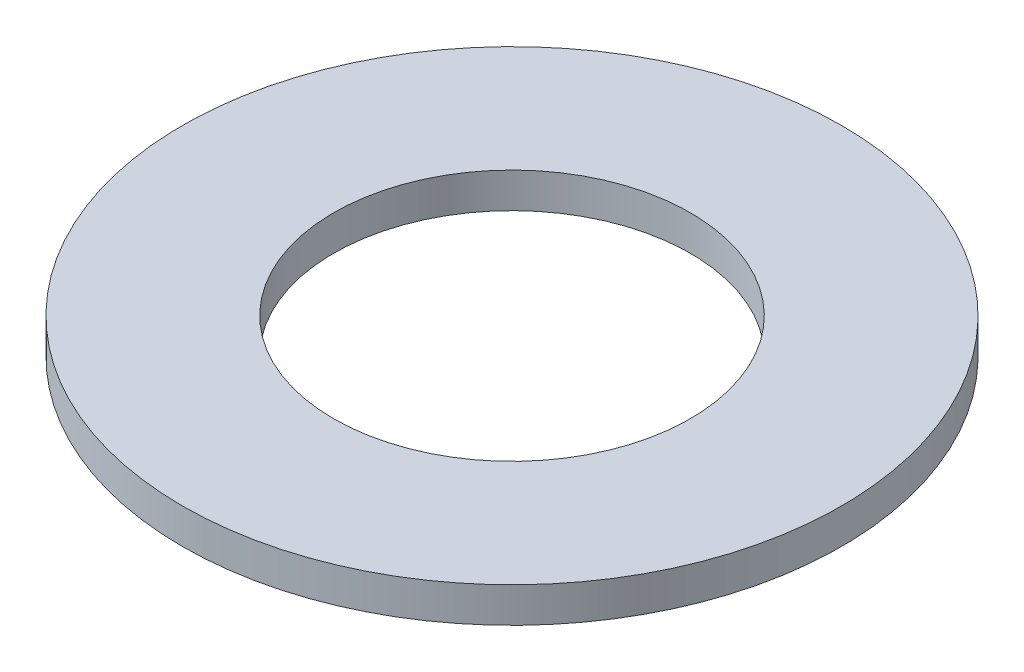
from build123d import *

# Parameters (mm, degrees)
SKETCH1_R           = 9.525
BOSS_EXTRUDE1_DEPTH = 1.016
SKETCH5_R           = 5.1562
CUT_EXTRUDE1_DEPTH  = 2.016


with BuildPart() as part:
    # Sketch1 → Boss-Extrude1 (new body)
    with BuildSketch(Plane(origin=(0, 0, 0), x_dir=(1, 0, 0), z_dir=(0, 1, 0))):
        Circle(SKETCH1_R)
    extrude(amount=BOSS_EXTRUDE1_DEPTH)

    # Sketch5 → Cut-Extrude1 (cut, through all)
    with BuildSketch(Plane(origin=(0, 1.016, 0), x_dir=(-1, 0, 0), z_dir=(0, 1, 0))):
        Circle(SKETCH5_R)
    extrude(amount=-CUT_EXTRUDE1_DEPTH, mode=Mode.SUBTRACT)


solid = part.part
